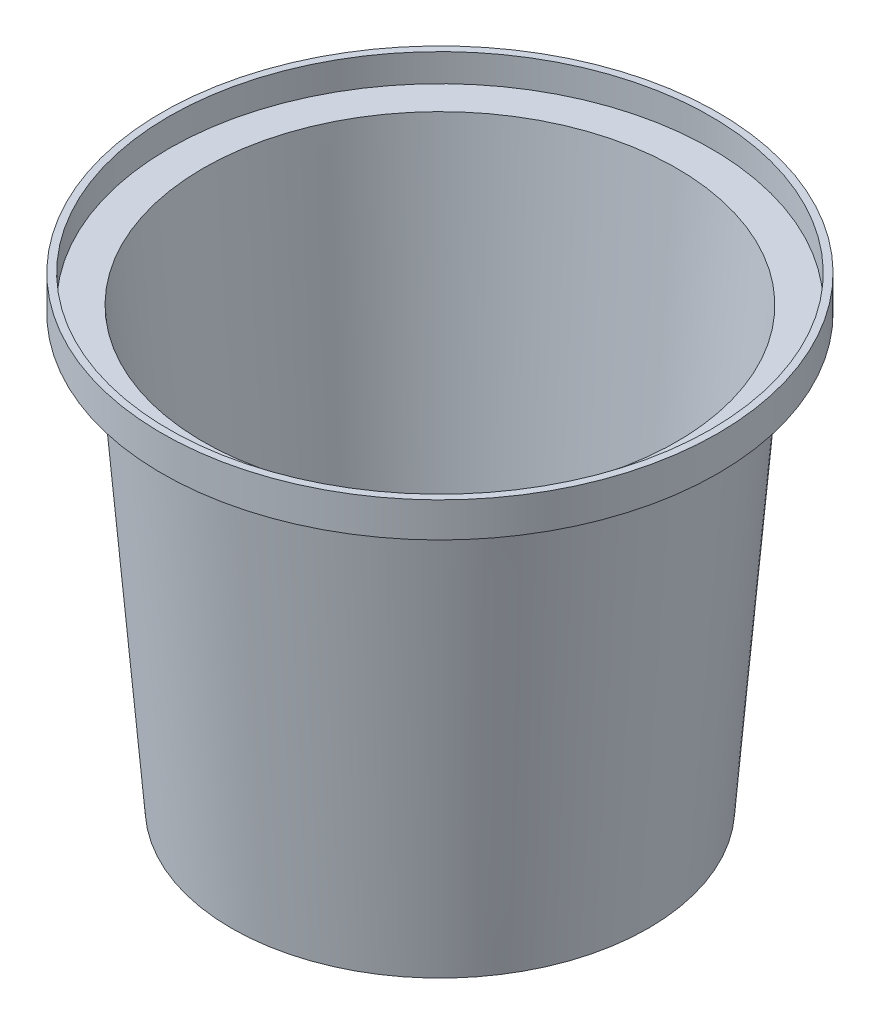
from build123d import *

# Parameters (mm, degrees)
SHELL_1_T = -3


with BuildPart() as part:
    # 草图1 → 旋转1 (revolve)
    with BuildSketch(Plane.XY, mode=Mode.PRIVATE) as revolve_1_sk:
        Polygon((0, 0), (-90, 0), (-105, 185), (-120, 185), (-120, 200), (0, 200), align=None)
    revolve(revolve_1_sk.sketch.rotate(Axis((0, -878.981608445, 0), (0, 1, 0)), 180), axis=Axis((0, -878.981608445, 0), (0, 1, 0)))

    # 抽壳1
    shell_1_openings = [part.faces().sort_by_distance(p)[0] for p in [
        (0, 200, 0),
    ]]
    offset(amount=SHELL_1_T, openings=shell_1_openings, kind=Kind.INTERSECTION)


solid = part.part
